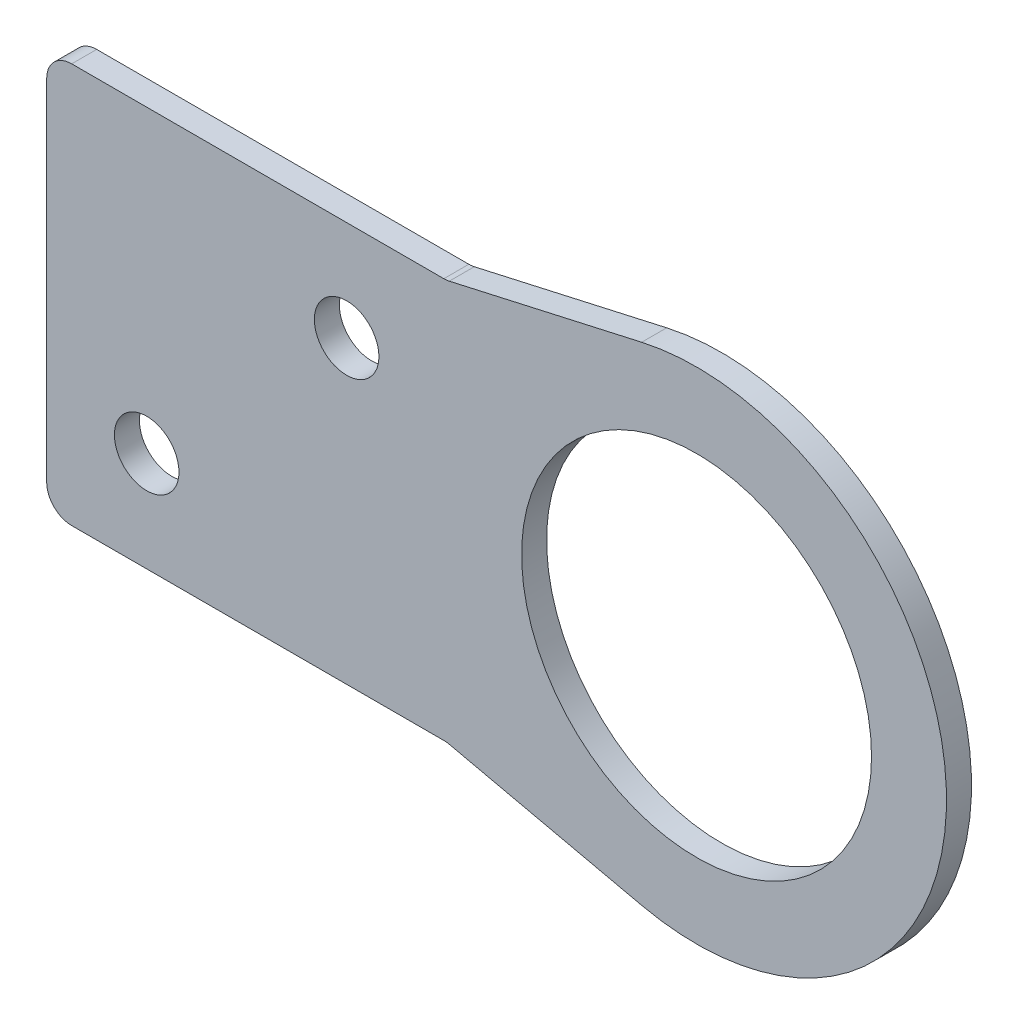
from build123d import *

# Parameters (mm, degrees)
SKETCH1_R           = 2.05
SKETCH1_R_2         = 15.875
SKETCH1_R_3         = 11.1125
BOSS_EXTRUDE1_DEPTH = 1.5875
FILLET1_R           = 1.5875


with BuildPart() as part:
    # Sketch1 → Boss-Extrude1 (new body)
    with BuildSketch(Plane.XY):
        Polygon((165.1, 12.7), (139.7, 12.7), (139.7, -12.7), (165.1, -12.7), (165.1, 3.4e-08), align=None)
        with Locations((146.05, -6.35)):
            Circle(SKETCH1_R, mode=Mode.SUBTRACT)
        with Locations((158.75, 6.35)):
            Circle(SKETCH1_R, mode=Mode.SUBTRACT)
        with BuildLine():
            Line((177.490243902, 15.487804878), (165.1, 12.7))
            Line((165.1, 12.7), (165.1, 3.4e-08))
            ThreePointArc((165.1, 3.4e-08), (168.578707661, 9.917033893), (177.490243902, 15.487804878))
        make_face()
        with Locations((180.975, 0)):
            Circle(SKETCH1_R_2)
        with Locations((180.975, 0)):
            Circle(SKETCH1_R_3, mode=Mode.SUBTRACT)
        with BuildLine():
            ThreePointArc((177.490243902, -15.487804878), (168.57870764, -9.917033867), (165.1, 3.4e-08))
            Line((165.1, 3.4e-08), (165.1, -12.7))
            Line((165.1, -12.7), (177.490243902, -15.487804878))
        make_face()
    extrude(amount=BOSS_EXTRUDE1_DEPTH)

    # Fillet1
    fillet1_edges = [part.edges().sort_by_distance(p)[0] for p in [
        (165.1, 12.7, 0.79375),
        (165.1, -12.7, 0.79375),
        (139.7, -12.7, 0.79375),
        (139.7, 12.7, 0.79375),
    ]]
    fillet(fillet1_edges, radius=FILLET1_R)


solid = part.part
